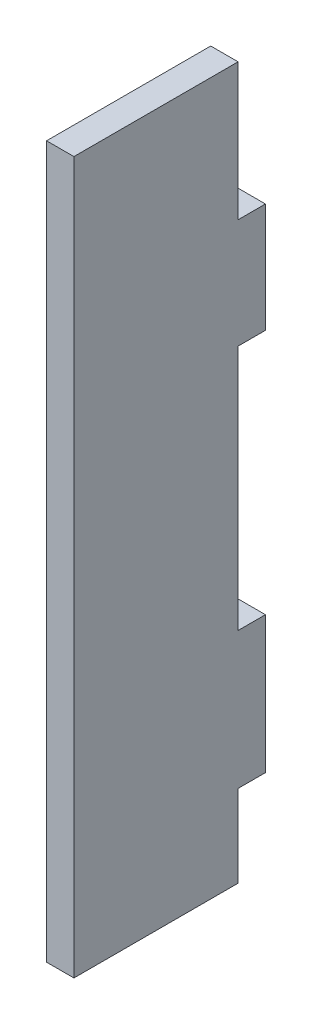
from build123d import *

# Parameters (mm, degrees)
SKETCH1_W             = 5
SKETCH1_H             = 20
BOSS_EXTRUDE1_DEPTH   = 5
SKETCH1_H_2           = 25
BOSS_EXTRUDE1_2_DEPTH = 5
SKETCH2_W             = 5
SKETCH2_H             = 130
BOSS_EXTRUDE2_DEPTH   = 30


with BuildPart() as part:
    # Sketch1 → Boss-Extrude1 (new body)
    with BuildSketch(Plane.XY):
        with Locations((-22.883589858, 35.86307718)):
            Rectangle(SKETCH1_W, SKETCH1_H)
    extrude(amount=BOSS_EXTRUDE1_DEPTH)



with BuildPart() as body_2:
    # Sketch1 → Boss-Extrude1 2 (new body)
    with BuildSketch(Plane.XY):
        with Locations((-22.883589858, -31.63692282)):
            Rectangle(SKETCH1_W, SKETCH1_H_2)
    extrude(amount=BOSS_EXTRUDE1_2_DEPTH)


with BuildPart() as part_1:
    add(part.part)

    add(body_2.part)  # Boss-Extrude2 merges body 2
    # Sketch2 → Boss-Extrude2 (add)
    with BuildSketch(Plane.XY.offset(5)):
        with Locations((-22.883589858, 5.86307718)):
            Rectangle(SKETCH2_W, SKETCH2_H)
    extrude(amount=BOSS_EXTRUDE2_DEPTH)


solid = part_1.part
